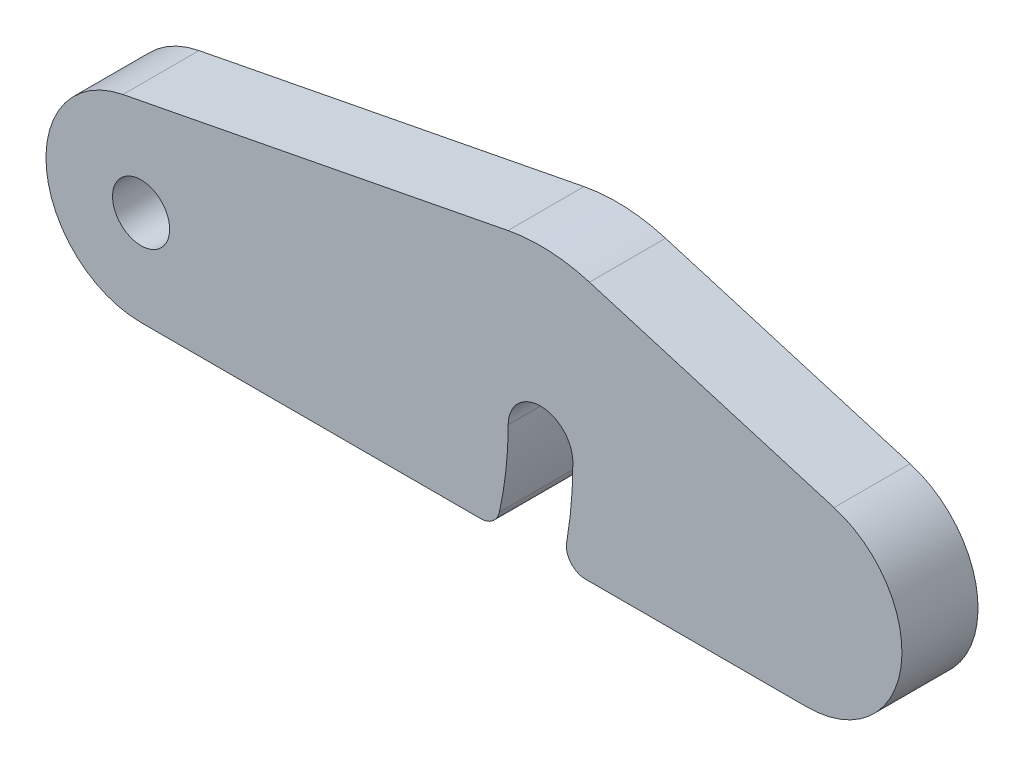
from build123d import *

# Parameters (mm, degrees)
SKETCH1_R           = 1.5
SKETCH1_R_2         = 1.7
BOSS_EXTRUDE1_DEPTH = 4
CUT_EXTRUDE1_DEPTH  = 5
FILLET1_R           = 1


with BuildPart() as part:
    # Sketch1 → Boss-Extrude1 (new body)
    with BuildSketch(Plane.XY):
        with BuildLine():
            Line((-17.976190476, -2.545770461), (17.023809524, -2.545770461))
            ThreePointArc((17.023809524, -2.545770461), (21.971428708, 1.732381628), (18.452380952, 7.245803777))
            Line((18.452380952, 7.245803777), (5.595238095, 11.079063167))
            ThreePointArc((5.595238095, 11.079063167), (3.465102786, 11.443404154), (1.30952381, 11.28945588))
            Line((1.30952381, 11.28945588), (-18.928571429, 7.362688617))
            ThreePointArc((-18.928571429, 7.362688617), (-22.953252631, 1.975844438), (-17.976190476, -2.545770461))
        make_face()
        with Locations((-17.976190476, 2.454229539)):
            Circle(SKETCH1_R, mode=Mode.SUBTRACT)
        with Locations((3.023809524, 2.454229539)):
            Circle(SKETCH1_R_2, mode=Mode.SUBTRACT)
    extrude(amount=BOSS_EXTRUDE1_DEPTH)

    # Sketch2 → Cut-Extrude1 (cut, through all)
    with BuildSketch(Plane.XY.offset(4)):
        with BuildLine():
            Line((-1.835195666, -8.126804745), (2.106929637, -8.126804745))
            ThreePointArc((2.106929637, -8.126804745), (4.059880255, -2.995686673), (4.723809524, 2.454229539))
            ThreePointArc((4.723809524, 2.454229539), (3.023809524, 4.154229539), (1.323809524, 2.454229539))
            ThreePointArc((1.323809524, 2.454229539), (0.517202937, -3.067038438), (-1.835195666, -8.126804745))
        make_face()
    extrude(amount=-CUT_EXTRUDE1_DEPTH, mode=Mode.SUBTRACT)

    # Fillet1
    fillet1_edges = [part.edges().sort_by_distance(p)[0] for p in [
        (4.166302608, -2.545770461, 2),
        (0.664893183, -2.545770461, 2),
    ]]
    fillet(fillet1_edges, radius=FILLET1_R)


solid = part.part
